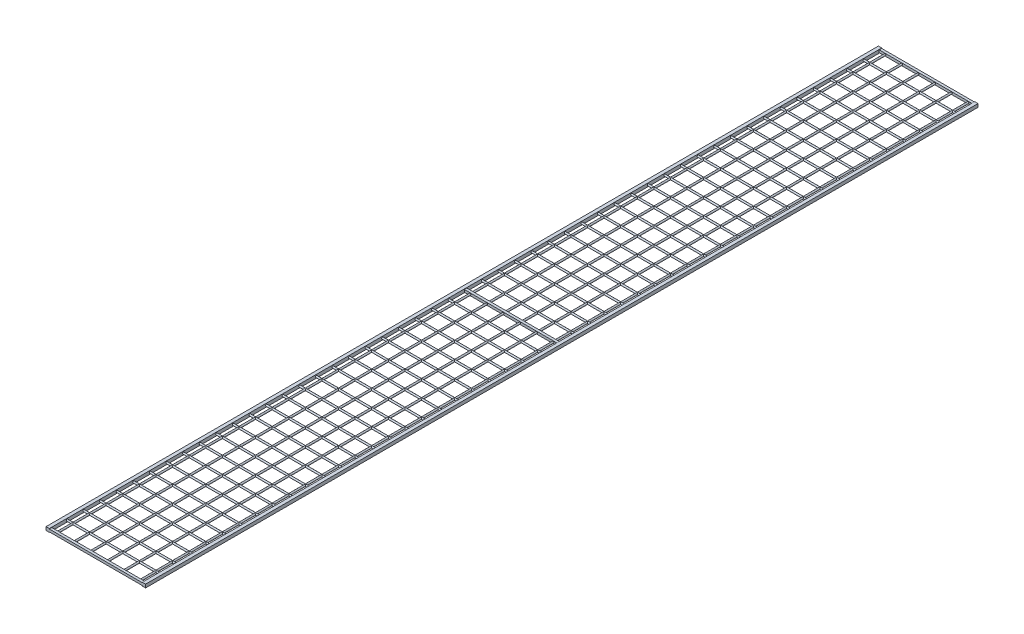
from build123d import *

# Parameters (mm, degrees)
SCHIZZO2_R                        = 2.5
ESTRUSIONE_ESTRUSIONE1_DEPTH      = 2500
ESTRUSIONE_ESTRUSIONE1_2_DEPTH    = 2500
ESTRUSIONE_ESTRUSIONE1_3_DEPTH    = 2500
ESTRUSIONE_ESTRUSIONE1_4_DEPTH    = 2500
ESTRUSIONE_ESTRUSIONE1_5_DEPTH    = 2500
ESTRUSIONE_ESTRUSIONE1_6_DEPTH    = 2500
ESTRUSIONE_ESTRUSIONE1_7_DEPTH    = 2500
ESTRUSIONE_ESTRUSIONE1_8_DEPTH    = 2500
ESTRUSIONE_ESTRUSIONE1_9_DEPTH    = 2500
ESTRUSIONE_ESTRUSIONE1_10_DEPTH   = 2500
ESTRUSIONE_ESTRUSIONE1_11_DEPTH   = 2500
ESTRUSIONE_ESTRUSIONE1_12_DEPTH   = 2500
ESTRUSIONE_ESTRUSIONE1_13_DEPTH   = 2500
ESTRUSIONE_ESTRUSIONE1_14_DEPTH   = 2500
ESTRUSIONE_ESTRUSIONE1_15_DEPTH   = 2500
ESTRUSIONE_ESTRUSIONE1_16_DEPTH   = 2500
ESTRUSIONE_ESTRUSIONE1_17_DEPTH   = 2500
ESTRUSIONE_ESTRUSIONE1_18_DEPTH   = 2500
ESTRUSIONE_ESTRUSIONE1_19_DEPTH   = 2500
SCHIZZO3_R                        = 2.5
ESTRUSIONE_ESTRUSIONE2_DEPTH      = 922.5
ESTRUSIONE_ESTRUSIONE2_DEPTH_BACK = 27.5
SCHIZZO5_W                        = 7.5
SCHIZZO5_H                        = 7.5
ESTRUSIONE_ESTRUSIONE3_DEPTH      = 950
SCHIZZO7_W                        = 10
SCHIZZO7_H                        = 10
ESTRUSIONE_ESTRUSIONE4_DEPTH      = 2507.5
SCHIZZO8_W                        = 673.132280392
SCHIZZO8_H                        = 74.352141311
TAGLIO_ESTRUSIONE1_DEPTH          = 2507.5
SCHIZZO9_W                        = 10
SCHIZZO9_H                        = 10
ESTRUSIONE_ESTRUSIONE5_DEPTH      = 2507.5


with BuildPart() as part:
    # Schizzo2 → Estrusione-Estrusione1 (new body)
    with BuildSketch(Plane.XY):
        Circle(SCHIZZO2_R)
    extrude(amount=ESTRUSIONE_ESTRUSIONE1_DEPTH)

    # Schizzo3 → Estrusione-Estrusione2 (add, two sides)
    with BuildSketch(Plane(origin=(0, 0, 0), x_dir=(0, 0, -1), z_dir=(1, 0, 0))) as estrusione_estrusione2_sk:
        Circle(SCHIZZO3_R)
        with Locations((-50, 0)):
            Circle(SCHIZZO3_R)
        with Locations((-100, 0)):
            Circle(SCHIZZO3_R)
        with Locations((-150, 0)):
            Circle(SCHIZZO3_R)
        with Locations((-200, 0)):
            Circle(SCHIZZO3_R)
        with Locations((-250, 0)):
            Circle(SCHIZZO3_R)
        with Locations((-300, 0)):
            Circle(SCHIZZO3_R)
        with Locations((-350, 0)):
            Circle(SCHIZZO3_R)
        with Locations((-400, 0)):
            Circle(SCHIZZO3_R)
        with Locations((-450, 0)):
            Circle(SCHIZZO3_R)
        with Locations((-500, 0)):
            Circle(SCHIZZO3_R)
        with Locations((-550, 0)):
            Circle(SCHIZZO3_R)
        with Locations((-600, 0)):
            Circle(SCHIZZO3_R)
        with Locations((-650, 0)):
            Circle(SCHIZZO3_R)
        with Locations((-700, 0)):
            Circle(SCHIZZO3_R)
        with Locations((-750, 0)):
            Circle(SCHIZZO3_R)
        with Locations((-800, 0)):
            Circle(SCHIZZO3_R)
        with Locations((-850, 0)):
            Circle(SCHIZZO3_R)
        with Locations((-900, 0)):
            Circle(SCHIZZO3_R)
        with Locations((-950, 0)):
            Circle(SCHIZZO3_R)
        with Locations((-1000, 0)):
            Circle(SCHIZZO3_R)
        with Locations((-1050, 0)):
            Circle(SCHIZZO3_R)
        with Locations((-1100, 0)):
            Circle(SCHIZZO3_R)
        with Locations((-1150, 0)):
            Circle(SCHIZZO3_R)
        with Locations((-1200, 0)):
            Circle(SCHIZZO3_R)
        with Locations((-1250, 0)):
            Circle(SCHIZZO3_R)
        with Locations((-1300, 0)):
            Circle(SCHIZZO3_R)
        with Locations((-1350, 0)):
            Circle(SCHIZZO3_R)
        with Locations((-1400, 0)):
            Circle(SCHIZZO3_R)
        with Locations((-1450, 0)):
            Circle(SCHIZZO3_R)
        with Locations((-1500, 0)):
            Circle(SCHIZZO3_R)
        with Locations((-1550, 0)):
            Circle(SCHIZZO3_R)
        with Locations((-1600, 0)):
            Circle(SCHIZZO3_R)
        with Locations((-1650, 0)):
            Circle(SCHIZZO3_R)
        with Locations((-1700, 0)):
            Circle(SCHIZZO3_R)
        with Locations((-1750, 0)):
            Circle(SCHIZZO3_R)
        with Locations((-1800, 0)):
            Circle(SCHIZZO3_R)
        with Locations((-1850, 0)):
            Circle(SCHIZZO3_R)
        with Locations((-1900, 0)):
            Circle(SCHIZZO3_R)
        with Locations((-1950, 0)):
            Circle(SCHIZZO3_R)
        with Locations((-2000, 0)):
            Circle(SCHIZZO3_R)
        with Locations((-2050, 0)):
            Circle(SCHIZZO3_R)
        with Locations((-2100, 0)):
            Circle(SCHIZZO3_R)
        with Locations((-2150, 0)):
            Circle(SCHIZZO3_R)
        with Locations((-2200, 0)):
            Circle(SCHIZZO3_R)
        with Locations((-2250, 0)):
            Circle(SCHIZZO3_R)
        with Locations((-2300, 0)):
            Circle(SCHIZZO3_R)
        with Locations((-2350, 0)):
            Circle(SCHIZZO3_R)
        with Locations((-2400, 0)):
            Circle(SCHIZZO3_R)
        with Locations((-2450, 0)):
            Circle(SCHIZZO3_R)
        with Locations((-2500, 0)):
            Circle(SCHIZZO3_R)
    extrude(amount=ESTRUSIONE_ESTRUSIONE2_DEPTH)
    extrude(estrusione_estrusione2_sk.sketch, amount=-ESTRUSIONE_ESTRUSIONE2_DEPTH_BACK)



with BuildPart() as body_2:
    # Schizzo2 → Estrusione-Estrusione1 2 (new body)
    with BuildSketch(Plane.XY):
        with Locations((50, 0)):
            Circle(SCHIZZO2_R)
    extrude(amount=ESTRUSIONE_ESTRUSIONE1_2_DEPTH)


with BuildPart() as body_3:
    # Schizzo2 → Estrusione-Estrusione1 3 (new body)
    with BuildSketch(Plane.XY):
        with Locations((100, 0)):
            Circle(SCHIZZO2_R)
    extrude(amount=ESTRUSIONE_ESTRUSIONE1_3_DEPTH)


with BuildPart() as body_4:
    # Schizzo2 → Estrusione-Estrusione1 4 (new body)
    with BuildSketch(Plane.XY):
        with Locations((150, 0)):
            Circle(SCHIZZO2_R)
    extrude(amount=ESTRUSIONE_ESTRUSIONE1_4_DEPTH)


with BuildPart() as body_5:
    # Schizzo2 → Estrusione-Estrusione1 5 (new body)
    with BuildSketch(Plane.XY):
        with Locations((200, 0)):
            Circle(SCHIZZO2_R)
    extrude(amount=ESTRUSIONE_ESTRUSIONE1_5_DEPTH)


with BuildPart() as body_6:
    # Schizzo2 → Estrusione-Estrusione1 6 (new body)
    with BuildSketch(Plane.XY):
        with Locations((250, 0)):
            Circle(SCHIZZO2_R)
    extrude(amount=ESTRUSIONE_ESTRUSIONE1_6_DEPTH)


with BuildPart() as body_7:
    # Schizzo2 → Estrusione-Estrusione1 7 (new body)
    with BuildSketch(Plane.XY):
        with Locations((300, 0)):
            Circle(SCHIZZO2_R)
    extrude(amount=ESTRUSIONE_ESTRUSIONE1_7_DEPTH)


with BuildPart() as body_8:
    # Schizzo2 → Estrusione-Estrusione1 8 (new body)
    with BuildSketch(Plane.XY):
        with Locations((350, 0)):
            Circle(SCHIZZO2_R)
    extrude(amount=ESTRUSIONE_ESTRUSIONE1_8_DEPTH)


with BuildPart() as body_9:
    # Schizzo2 → Estrusione-Estrusione1 9 (new body)
    with BuildSketch(Plane.XY):
        with Locations((400, 0)):
            Circle(SCHIZZO2_R)
    extrude(amount=ESTRUSIONE_ESTRUSIONE1_9_DEPTH)


with BuildPart() as body_10:
    # Schizzo2 → Estrusione-Estrusione1 10 (new body)
    with BuildSketch(Plane.XY):
        with Locations((450, 0)):
            Circle(SCHIZZO2_R)
    extrude(amount=ESTRUSIONE_ESTRUSIONE1_10_DEPTH)


with BuildPart() as body_11:
    # Schizzo2 → Estrusione-Estrusione1 11 (new body)
    with BuildSketch(Plane.XY):
        with Locations((500, 0)):
            Circle(SCHIZZO2_R)
    extrude(amount=ESTRUSIONE_ESTRUSIONE1_11_DEPTH)


with BuildPart() as body_12:
    # Schizzo2 → Estrusione-Estrusione1 12 (new body)
    with BuildSketch(Plane.XY):
        with Locations((550, 0)):
            Circle(SCHIZZO2_R)
    extrude(amount=ESTRUSIONE_ESTRUSIONE1_12_DEPTH)


with BuildPart() as body_13:
    # Schizzo2 → Estrusione-Estrusione1 13 (new body)
    with BuildSketch(Plane.XY):
        with Locations((600, 0)):
            Circle(SCHIZZO2_R)
    extrude(amount=ESTRUSIONE_ESTRUSIONE1_13_DEPTH)


with BuildPart() as body_14:
    # Schizzo2 → Estrusione-Estrusione1 14 (new body)
    with BuildSketch(Plane.XY):
        with Locations((650, 0)):
            Circle(SCHIZZO2_R)
    extrude(amount=ESTRUSIONE_ESTRUSIONE1_14_DEPTH)


with BuildPart() as body_15:
    # Schizzo2 → Estrusione-Estrusione1 15 (new body)
    with BuildSketch(Plane.XY):
        with Locations((700, 0)):
            Circle(SCHIZZO2_R)
    extrude(amount=ESTRUSIONE_ESTRUSIONE1_15_DEPTH)


with BuildPart() as body_16:
    # Schizzo2 → Estrusione-Estrusione1 16 (new body)
    with BuildSketch(Plane.XY):
        with Locations((750, 0)):
            Circle(SCHIZZO2_R)
    extrude(amount=ESTRUSIONE_ESTRUSIONE1_16_DEPTH)


with BuildPart() as body_17:
    # Schizzo2 → Estrusione-Estrusione1 17 (new body)
    with BuildSketch(Plane.XY):
        with Locations((800, 0)):
            Circle(SCHIZZO2_R)
    extrude(amount=ESTRUSIONE_ESTRUSIONE1_17_DEPTH)


with BuildPart() as body_18:
    # Schizzo2 → Estrusione-Estrusione1 18 (new body)
    with BuildSketch(Plane.XY):
        with Locations((850, 0)):
            Circle(SCHIZZO2_R)
    extrude(amount=ESTRUSIONE_ESTRUSIONE1_18_DEPTH)


with BuildPart() as body_19:
    # Schizzo2 → Estrusione-Estrusione1 19 (new body)
    with BuildSketch(Plane.XY):
        with Locations((900, 0)):
            Circle(SCHIZZO2_R)
    extrude(amount=ESTRUSIONE_ESTRUSIONE1_19_DEPTH)


with BuildPart() as part_1:
    add(part.part)

    add(body_2.part)  # Estrusione-Estrusione3 merges body 2

    add(body_3.part)  # Estrusione-Estrusione3 merges body 3

    add(body_4.part)  # Estrusione-Estrusione3 merges body 4

    add(body_5.part)  # Estrusione-Estrusione3 merges body 5

    add(body_6.part)  # Estrusione-Estrusione3 merges body 6

    add(body_7.part)  # Estrusione-Estrusione3 merges body 7

    add(body_8.part)  # Estrusione-Estrusione3 merges body 8

    add(body_9.part)  # Estrusione-Estrusione3 merges body 9

    add(body_10.part)  # Estrusione-Estrusione3 merges body 10

    add(body_11.part)  # Estrusione-Estrusione3 merges body 11

    add(body_12.part)  # Estrusione-Estrusione3 merges body 12

    add(body_13.part)  # Estrusione-Estrusione3 merges body 13

    add(body_14.part)  # Estrusione-Estrusione3 merges body 14

    add(body_15.part)  # Estrusione-Estrusione3 merges body 15

    add(body_16.part)  # Estrusione-Estrusione3 merges body 16

    add(body_17.part)  # Estrusione-Estrusione3 merges body 17

    add(body_18.part)  # Estrusione-Estrusione3 merges body 18

    add(body_19.part)  # Estrusione-Estrusione3 merges body 19
    # Schizzo5 → Estrusione-Estrusione3 (add)
    with BuildSketch(Plane.ZY.offset(27.5)):
        with Locations((1250, 0)):
            Rectangle(SCHIZZO5_W, SCHIZZO5_H)
        Rectangle(SCHIZZO5_W, SCHIZZO5_H)
        with Locations((2500, 0)):
            Rectangle(SCHIZZO5_W, SCHIZZO5_H)
    extrude(amount=-ESTRUSIONE_ESTRUSIONE3_DEPTH)

    # Schizzo7 → Estrusione-Estrusione4 (add)
    with BuildSketch(Plane(origin=(0, 0, -3.75), x_dir=(-1, 0, 0), z_dir=(0, 0, -1))):
        with Locations((22.5, 0)):
            Rectangle(SCHIZZO7_W, SCHIZZO7_H)
        with Locations((-917.5, 0)):
            Rectangle(SCHIZZO7_W, SCHIZZO7_H)
    extrude(amount=-ESTRUSIONE_ESTRUSIONE4_DEPTH)

    # Schizzo8 → Taglio-Estrusione1 (cut)
    with BuildSketch(Plane.XY.offset(2503.75)):
        with Locations((609.066140196, -12.608392488)):
            Rectangle(SCHIZZO8_W, SCHIZZO8_H)
    extrude(amount=-TAGLIO_ESTRUSIONE1_DEPTH, mode=Mode.SUBTRACT)

    # Schizzo9 → Estrusione-Estrusione5 (add)
    with BuildSketch(Plane.XY.offset(2503.75)):
        with Locations((267.5, 0)):
            Rectangle(SCHIZZO9_W, SCHIZZO9_H)
    extrude(amount=-ESTRUSIONE_ESTRUSIONE5_DEPTH)


solid = part_1.part
